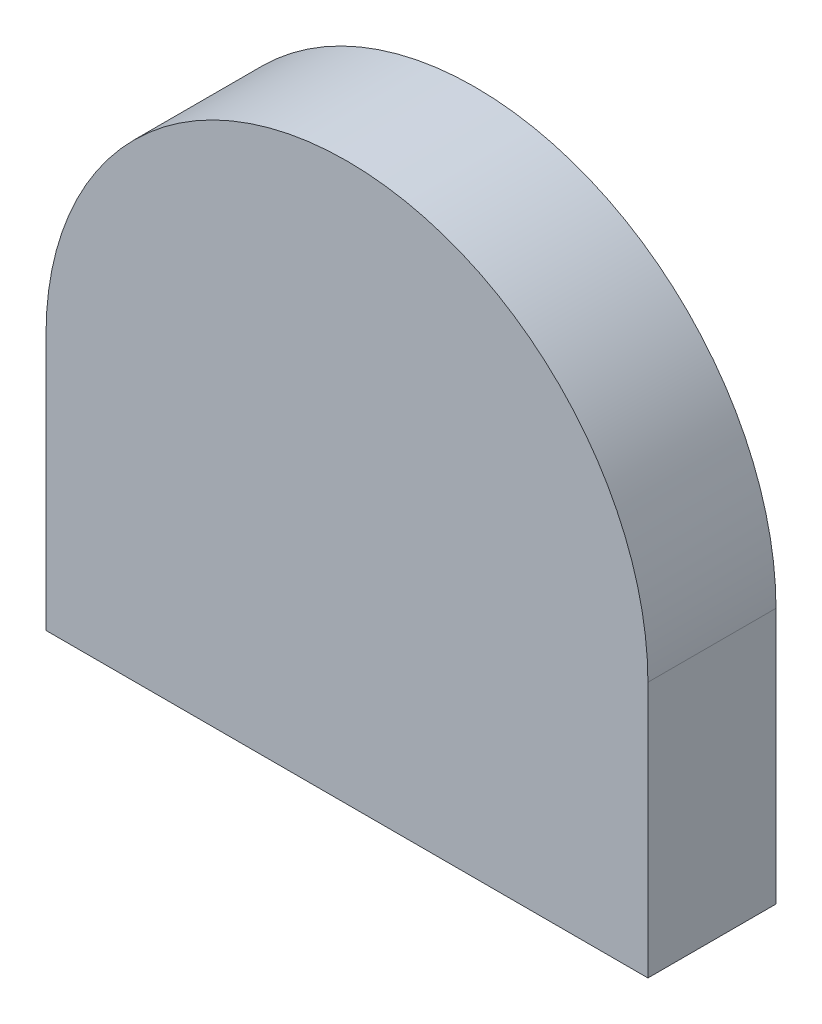
from build123d import *

# Parameters (mm, degrees)
DODANIE_WYCI_GNI_CIE1_DEPTH = 10


with BuildPart() as part:
    # Szkic1 → Dodanie-wyciągnięcie1 (new body)
    with BuildSketch(Plane.XY):
        with BuildLine():
            Line((0, 0), (47, 0))
            Line((47, 0), (47, 20))
            ThreePointArc((47, 20), (23.5, 43.5), (0, 20))
            Line((0, 20), (0, 0))
        make_face()
    extrude(amount=DODANIE_WYCI_GNI_CIE1_DEPTH)


solid = part.part
